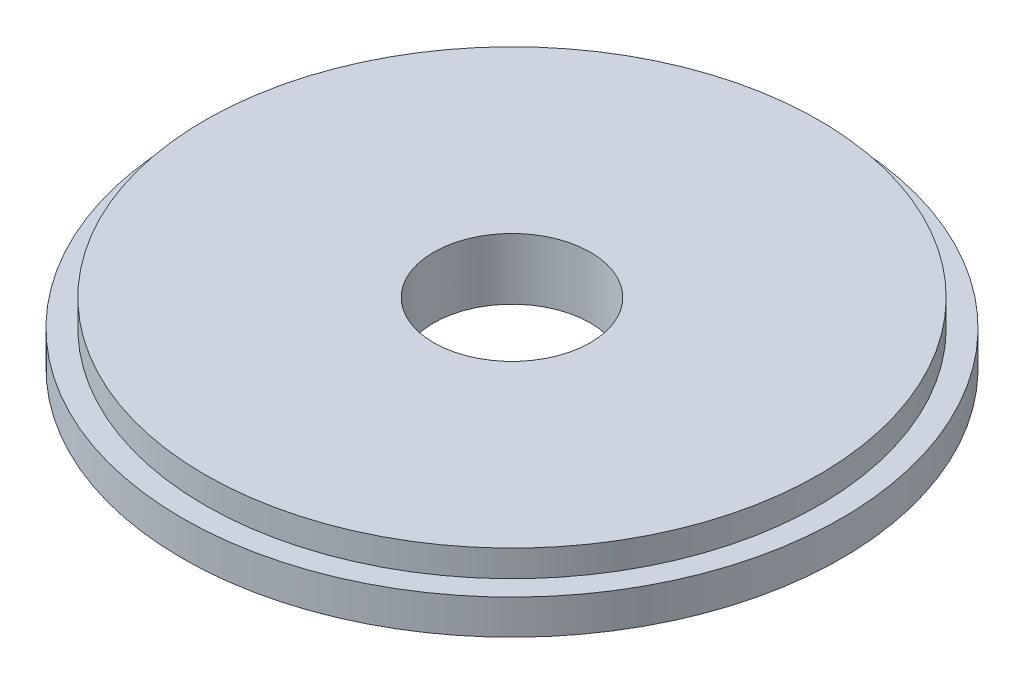
from build123d import *

# Parameters (mm, degrees)
SKETCH1_R           = 27.325
BOSS_EXTRUDE1_DEPTH = 2.8829
SKETCH2_R           = 25.45715
BOSS_EXTRUDE2_DEPTH = 2.1971
SKETCH6_R           = 6.500596607
CUT_EXTRUDE1_DEPTH  = 25.4


with BuildPart() as part:
    # Sketch1 → Boss-Extrude1 (new body)
    with BuildSketch(Plane(origin=(0, 0, 0), x_dir=(1, 0, 0), z_dir=(0, 1, 0))):
        Circle(SKETCH1_R)
    extrude(amount=BOSS_EXTRUDE1_DEPTH)

    # Sketch2 → Boss-Extrude2 (add)
    with BuildSketch(Plane(origin=(0, 2.8829, 0), x_dir=(1, 0, 0), z_dir=(0, 1, 0))):
        Circle(SKETCH2_R)
    extrude(amount=BOSS_EXTRUDE2_DEPTH)

    # Sketch6 → Cut-Extrude1 (cut)
    with BuildSketch(Plane.XZ):
        Circle(SKETCH6_R)
    extrude(amount=-CUT_EXTRUDE1_DEPTH, mode=Mode.SUBTRACT)


solid = part.part
